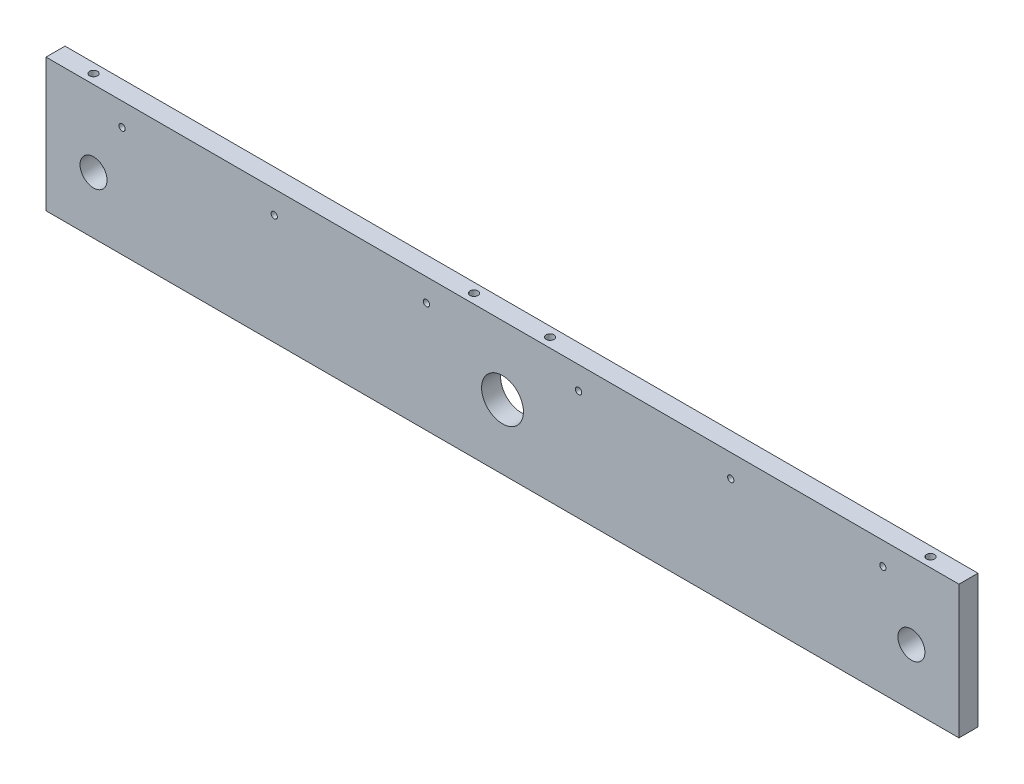
from build123d import *

# Parameters (mm, degrees)
SKETCH1_W                  = 480
SKETCH1_H                  = 70
SKETCH1_R                  = 11
SKETCH1_R_2                = 7.1
BOSS_EXTRUDE1_DEPTH        = 10
M5_TAPPED_HOLE1_D          = 4.2
M5_TAPPED_HOLE1_DEPTH      = 10
M5_TAPPED_HOLE1_TIP        = 1.2618073
M5_TAPPED_HOLE2_D          = 4.2
M5_TAPPED_HOLE2_DEPTH      = 12.4
M5_TAPPED_HOLE2_TIP        = 1.2618073
F_3_3_3_3_DIAMETER_HOLE1_D = 3.3


with BuildPart() as part:
    # Sketch1 → Boss-Extrude1 (new body)
    with BuildSketch(Plane.XY):
        Rectangle(SKETCH1_W, SKETCH1_H)
        with Locations((0, -1)):
            Circle(SKETCH1_R, mode=Mode.SUBTRACT)
        with Locations((-215, -5)):
            Circle(SKETCH1_R_2, mode=Mode.SUBTRACT)
        with Locations((215, -5)):
            Circle(SKETCH1_R_2, mode=Mode.SUBTRACT)
    extrude(amount=BOSS_EXTRUDE1_DEPTH)

    # M5 Tapped Hole1
    with Locations(Plane(origin=(0, 35, 0), x_dir=(1, 0, 0), z_dir=(0, 1, 0))):
        with Locations((220, -5), (-220, -5), (-20, -5), (20, -5)):
            Hole(M5_TAPPED_HOLE1_D / 2, depth=M5_TAPPED_HOLE1_DEPTH)
            with Locations((0, 0, -(M5_TAPPED_HOLE1_DEPTH + M5_TAPPED_HOLE1_TIP / 2))):  # 118° drill point
                Cone(0, M5_TAPPED_HOLE1_D / 2, M5_TAPPED_HOLE1_TIP, mode=Mode.SUBTRACT)

    # M5 Tapped Hole2
    with Locations(Plane(origin=(0, -35, 0), x_dir=(-1, 0, 0), z_dir=(0, -1, 0))):
        with Locations((-220, -5), (220, -5)):
            Hole(M5_TAPPED_HOLE2_D / 2, depth=M5_TAPPED_HOLE2_DEPTH)
            with Locations((0, 0, -(M5_TAPPED_HOLE2_DEPTH + M5_TAPPED_HOLE2_TIP / 2))):  # 118° drill point
                Cone(0, M5_TAPPED_HOLE2_D / 2, M5_TAPPED_HOLE2_TIP, mode=Mode.SUBTRACT)

    # Ø3.3 (3.3) Diameter Hole1 (through all)
    with Locations(Plane.XY.offset(10)):
        with Locations((-200, 23), (-120, 23), (-40, 23), (40, 23), (120, 23), (200, 23)):
            Hole(F_3_3_3_3_DIAMETER_HOLE1_D / 2)


solid = part.part
